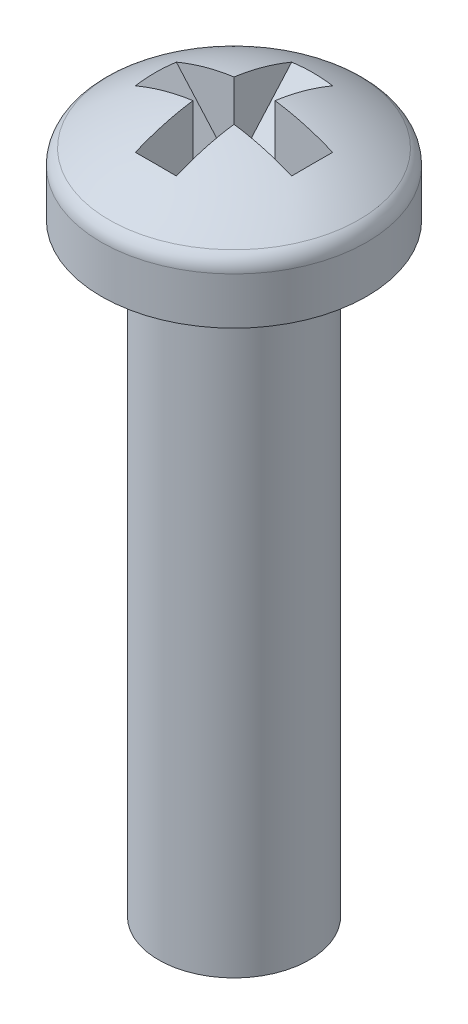
from build123d import *

# Parameters (mm, degrees)
SKETCH2_W          = 1.5875
SKETCH2_H          = 12.7
CUT_EXTRUDE1_DEPTH = 0.4318
CUT_EXTRUDE2_DEPTH = 0.4318


with BuildPart() as part:
    # Sketch1 → Base-Revolve (revolve)
    with BuildSketch(Plane.XY):
        with BuildLine():
            Line((0, 0), (2.794, 0))
            Line((2.794, 0), (2.794, 0.988051987))
            ThreePointArc((2.794, 0.988051987), (2.749892337, 1.170116122), (2.627350358, 1.311806977))
            ThreePointArc((2.627350358, 1.311806977), (1.379087386, 1.963971758), (0, 2.249624225))
            Line((0, 2.249624225), (0, 0))
        make_face()
    revolve(axis=Axis((0, 0, 0), (0, 1, 0)))

    # Sketch2 → Boss-Revolve1 (revolve)
    with BuildSketch(Plane.XY):
        with Locations((0.79375, -6.35)):
            Rectangle(SKETCH2_W, SKETCH2_H)
    revolve(axis=Axis((0, 0, 0), (0, 1, 0)))

    # Sketch3 → Cut-Extrude1 (cut, symmetric)
    with BuildSketch(Plane.XY):
        Polygon((-2.0193, 3.3909), (2.0193, 3.3909), (2.0193, 2.2606), (0, -0.0254), (-2.0193, 2.2606), align=None)
    extrude(amount=CUT_EXTRUDE1_DEPTH, both=True, mode=Mode.SUBTRACT)

    # Sketch4 → Cut-Extrude2 (cut, symmetric)
    with BuildSketch(Plane(origin=(0, 0, 0), x_dir=(0, 0, -1), z_dir=(1, 0, 0))):
        Polygon((-2.0193, 3.3909), (2.0193, 3.3909), (2.0193, 2.2606), (0, -0.0254), (-2.0193, 2.2606), align=None)
    extrude(amount=CUT_EXTRUDE2_DEPTH, both=True, mode=Mode.SUBTRACT)


solid = part.part
